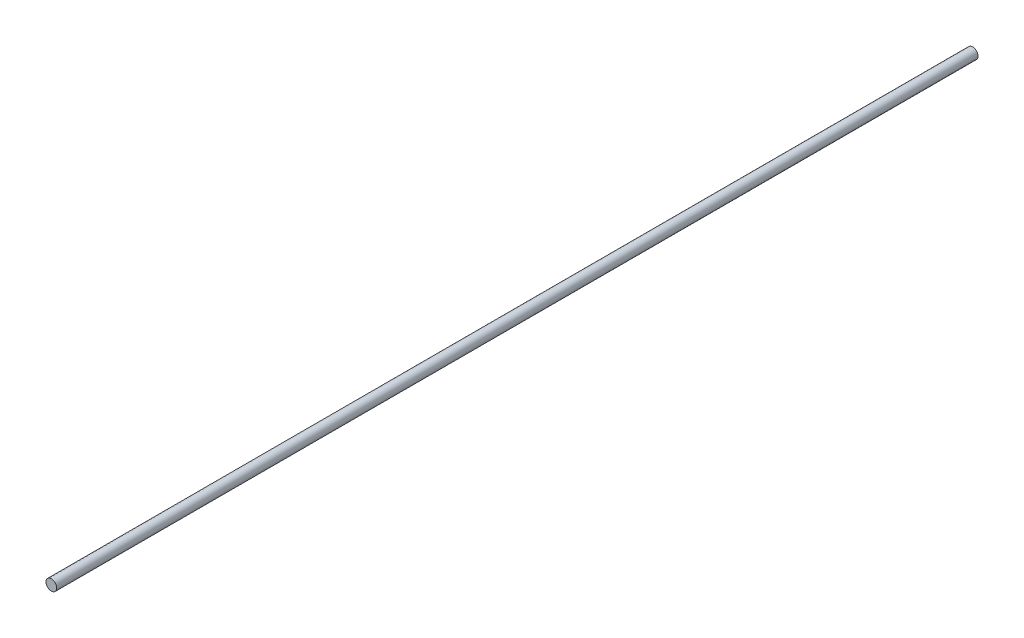
from build123d import *

# Parameters (mm, degrees)
ESQUISSE1_R        = 4
BOSS_EXTRU_1_DEPTH = 688


with BuildPart() as part:
    # Esquisse1 → Boss.-Extru.1 (new body)
    with BuildSketch(Plane.XY):
        Circle(ESQUISSE1_R)
    extrude(amount=BOSS_EXTRU_1_DEPTH)


solid = part.part
